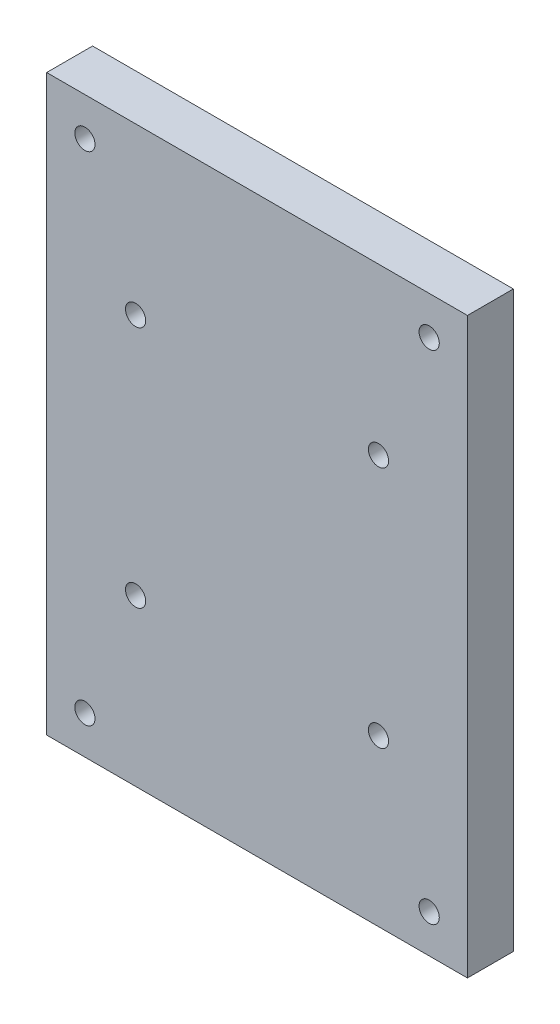
from build123d import *

# Parameters (mm, degrees)
SKETCH1_W           = 55
SKETCH1_H           = 75
SKETCH1_R           = 1.32
BOSS_EXTRUDE1_DEPTH = 6
SKETCH2_R           = 3.25
CUT_EXTRUDE1_DEPTH  = 4


with BuildPart() as part:
    # Sketch1 → Boss-Extrude1 (new body)
    with BuildSketch(Plane.XY):
        with Locations((-27.5, -37.5)):
            Rectangle(SKETCH1_W, SKETCH1_H)
        with Locations((-43.375, -21.625)):
            Circle(SKETCH1_R, mode=Mode.SUBTRACT)
        with Locations((-11.625, -21.625)):
            Circle(SKETCH1_R, mode=Mode.SUBTRACT)
        with Locations((-11.625, -53.375)):
            Circle(SKETCH1_R, mode=Mode.SUBTRACT)
        with Locations((-43.375, -53.375)):
            Circle(SKETCH1_R, mode=Mode.SUBTRACT)
        with Locations((-50, -5)):
            Circle(SKETCH1_R, mode=Mode.SUBTRACT)
        with Locations((-5, -5)):
            Circle(SKETCH1_R, mode=Mode.SUBTRACT)
        with Locations((-5, -70)):
            Circle(SKETCH1_R, mode=Mode.SUBTRACT)
        with Locations((-50, -70)):
            Circle(SKETCH1_R, mode=Mode.SUBTRACT)
    extrude(amount=BOSS_EXTRUDE1_DEPTH)

    # Sketch2 → Cut-Extrude1 (cut)
    with BuildSketch(Plane(origin=(0, 0, 0), x_dir=(-1, 0, 0), z_dir=(0, 0, -1))):
        with Locations((11.625, -21.625)):
            Circle(SKETCH2_R)
        with Locations((43.375, -21.625)):
            Circle(SKETCH2_R)
        with Locations((43.375, -53.375)):
            Circle(SKETCH2_R)
        with Locations((11.625, -53.375)):
            Circle(SKETCH2_R)
    extrude(amount=-CUT_EXTRUDE1_DEPTH, mode=Mode.SUBTRACT)


solid = part.part
